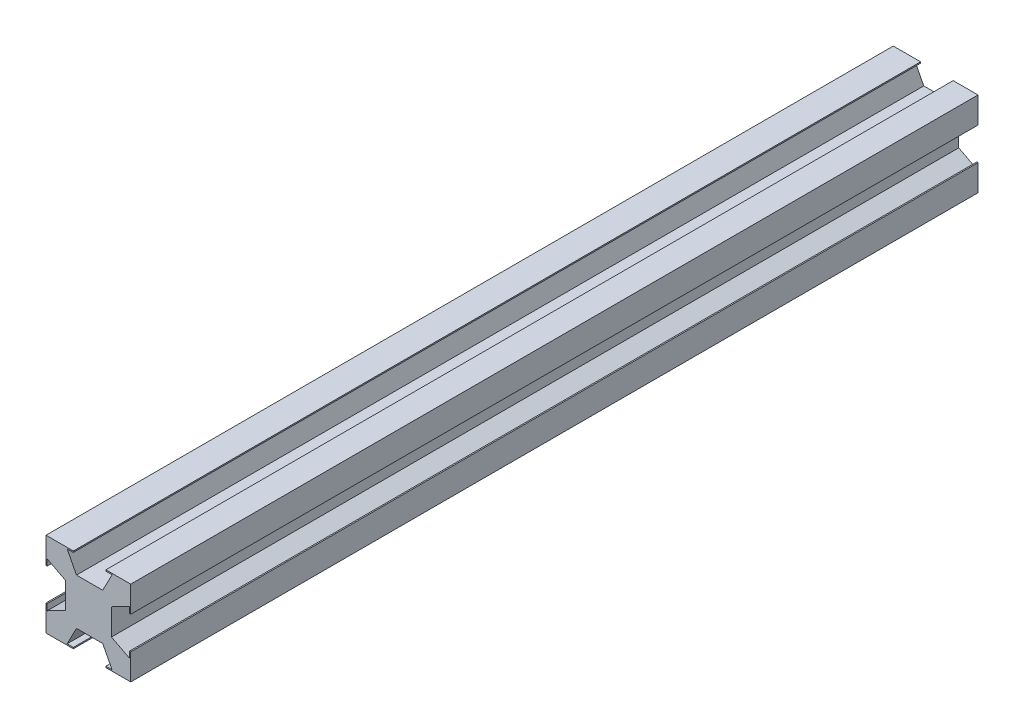
from build123d import *

# Parameters (mm, degrees)
Y_KSEKLIK_EKSTR_ZYON1_DEPTH = 200
Y_KSEKLIK_EKSTR_ZYON3_DEPTH = 200


with BuildPart() as part:
    # Çizim1 → Yükseklik-Ekstrüzyon1 (new body)
    with BuildSketch(Plane.XY):
        Polygon((-5.15760167, 10), (-2.80302277, 5.444963707), (3.391667495, 5.444963707), (5.746246396, 10), (10, 10), (10, 5.45), (5.445076204, 3.095), (5.445076204, -3.095), (10, -5.45), (10, -10), (5.746246396, -10), (3.391667495, -5.444963707), (-2.80302277, -5.444963707), (-5.15760167, -10), (-10, -10), (-10, -5.45), (-5.445076204, -3.095), (-5.445076204, 3.095), (-10, 5.45), (-10, 10), align=None)
    extrude(amount=Y_KSEKLIK_EKSTR_ZYON1_DEPTH)

    # Çizim4 → Yükseklik-Ekstrüzyon3 (add)
    with BuildSketch(Plane.XY.offset(200)):
        Polygon((-5.15760167, 10), (-3.54995598, 10), (-3.54995598, 9.705121592), (-5.005173801, 9.705121592), align=None)
        Polygon((10, 3.84), (9.71, 3.84), (9.71, 5.300063353), (10, 5.45), align=None)
        Polygon((5.593818526, 9.705121592), (5.746246396, 10), (4.138600705, 10), (4.138600705, 9.705121592), align=None)
        Polygon((5.746246396, -10), (4.138600705, -10), (4.138600705, -9.705121592), (5.593818526, -9.705121592), align=None)
        Polygon((-5.005173801, -9.705121592), (-5.15760167, -10), (-3.54995598, -10), (-3.54995598, -9.705121592), align=None)
        Polygon((-10, 5.45), (-10, 3.84), (-9.71, 3.84), (-9.71, 5.300063353), align=None)
        Polygon((9.71, -5.300063353), (10, -5.45), (10, -3.84), (9.71, -3.84), align=None)
        Polygon((-9.71, -5.300063353), (-10, -5.45), (-10, -3.84), (-9.71, -3.84), align=None)
    extrude(amount=-Y_KSEKLIK_EKSTR_ZYON3_DEPTH)


solid = part.part
